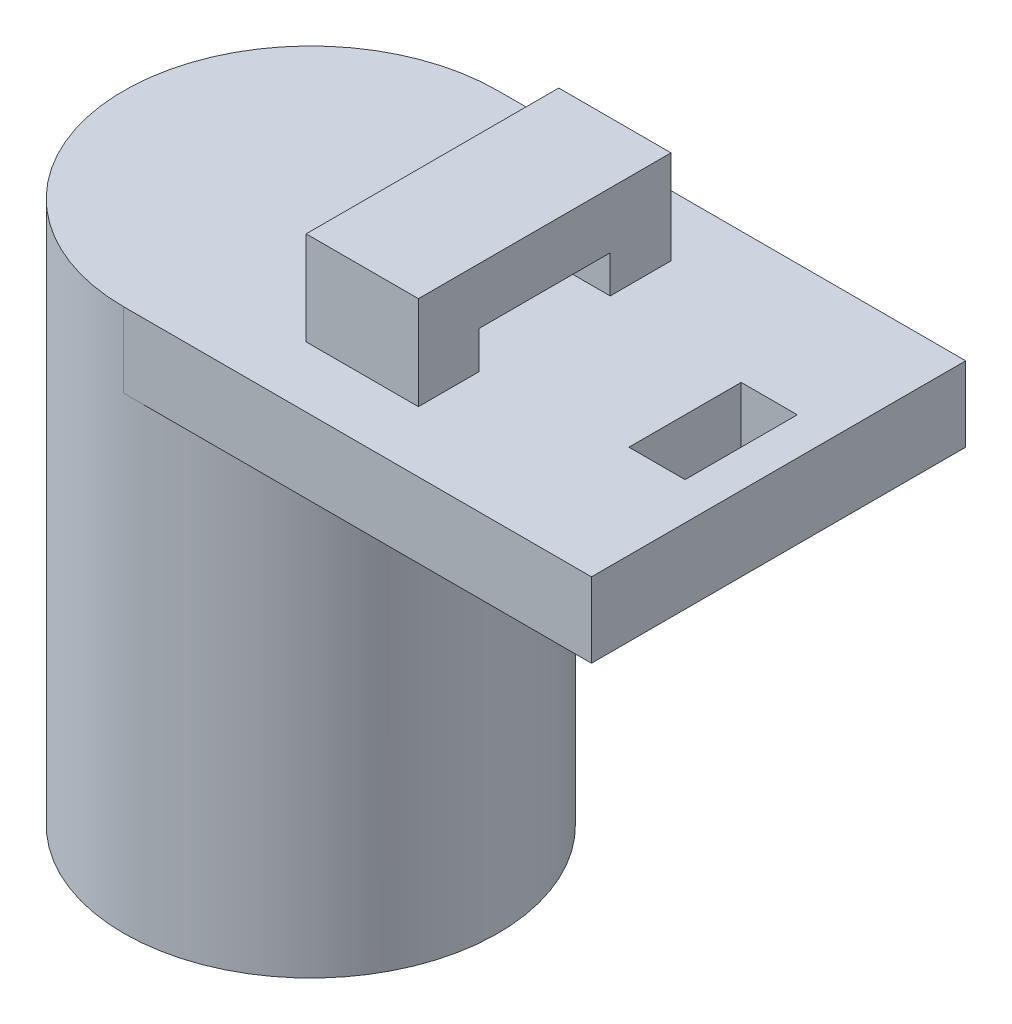
from build123d import *

# Parameters (mm, degrees)
SKETCH1_R           = 10
SKETCH1_R_2         = 6.5
BOSS_EXTRUDE1_DEPTH = 25
BOSS_EXTRUDE2_DEPTH = 4
SKETCH3_W           = 6
SKETCH3_H           = 13.5
BOSS_EXTRUDE3_DEPTH = 5
SKETCH4_W           = 7
SKETCH4_H           = 2
CUT_EXTRUDE1_DEPTH  = 12
SKETCH5_W           = 3
SKETCH5_H           = 6
CUT_EXTRUDE2_DEPTH  = 12


with BuildPart() as part:
    # Sketch1 → Boss-Extrude1 (new body)
    with BuildSketch(Plane(origin=(0, 0, 0), x_dir=(1, 0, 0), z_dir=(0, 1, 0))):
        Circle(SKETCH1_R)
        Circle(SKETCH1_R_2, mode=Mode.SUBTRACT)
    extrude(amount=BOSS_EXTRUDE1_DEPTH)

    # Sketch2 → Boss-Extrude2 (add)
    with BuildSketch(Plane(origin=(0, 25, 0), x_dir=(1, 0, 0), z_dir=(0, 1, 0))):
        with BuildLine():
            Line((0, 10), (25, 10))
            Line((25, 10), (25, -10))
            Line((25, -10), (0, -10))
            ThreePointArc((0, -10), (-10, 0), (0, 10))
        make_face()
    extrude(amount=BOSS_EXTRUDE2_DEPTH)

    # Sketch3 → Boss-Extrude3 (add)
    with BuildSketch(Plane(origin=(0, 29, 0), x_dir=(1, 0, 0), z_dir=(0, 1, 0))):
        with Locations((9.5, 0)):
            Rectangle(SKETCH3_W, SKETCH3_H)
    extrude(amount=BOSS_EXTRUDE3_DEPTH)

    # Sketch4 → Cut-Extrude1 (cut)
    with BuildSketch(Plane(origin=(12.5, 0, 0), x_dir=(0, 0, -1), z_dir=(1, 0, 0))):
        with Locations((0, 30)):
            Rectangle(SKETCH4_W, SKETCH4_H)
    extrude(amount=-CUT_EXTRUDE1_DEPTH, mode=Mode.SUBTRACT)

    # Sketch5 → Cut-Extrude2 (cut)
    with BuildSketch(Plane(origin=(0, 29, 0), x_dir=(1, 0, 0), z_dir=(0, 1, 0))):
        with Locations((21.5, 0)):
            Rectangle(SKETCH5_W, SKETCH5_H)
    extrude(amount=-CUT_EXTRUDE2_DEPTH, mode=Mode.SUBTRACT)


solid = part.part
